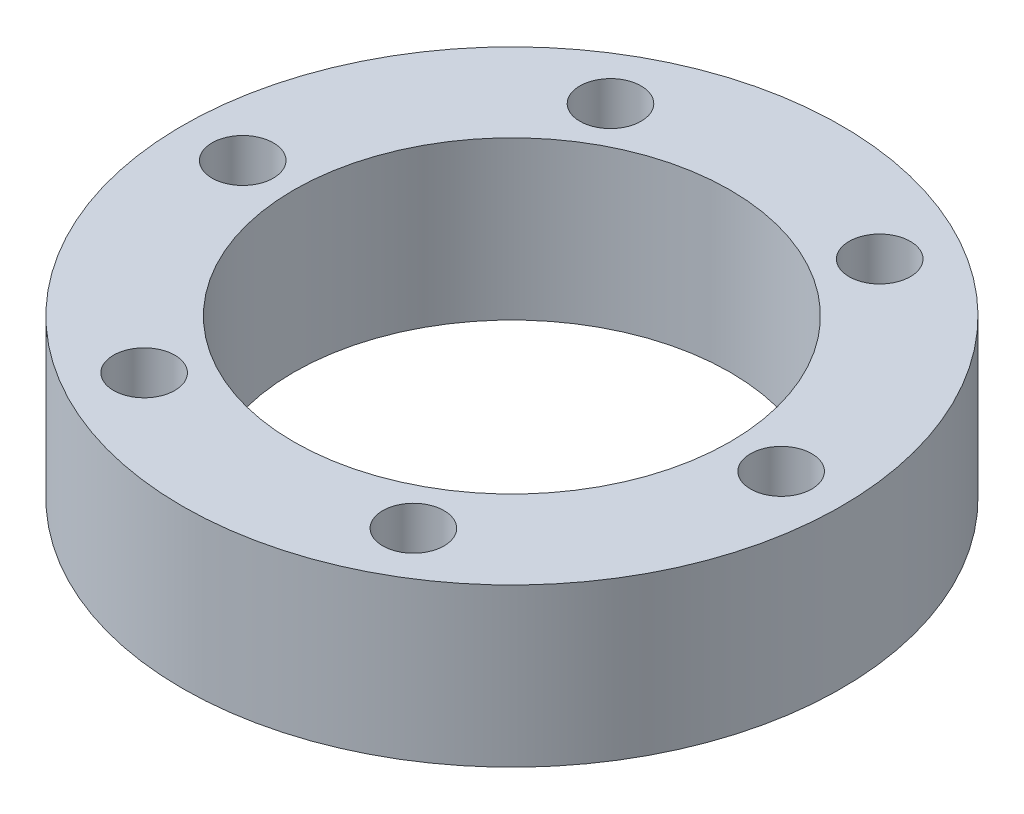
from build123d import *

# Parameters (mm, degrees)
SKETCH1_R                = 35.5
SKETCH1_R_2              = 23.5
BOSS_EXTRUDE1_DEPTH      = 17
M6_CLEARANCE_HOLE1_D     = 6.6
M6_CLEARANCE_HOLE1_DEPTH = 17
CIRPATTERN1_COUNT        = 6


with BuildPart() as part:
    # Sketch1 → Boss-Extrude1 (new body)
    with BuildSketch(Plane(origin=(0, 0, 0), x_dir=(1, 0, 0), z_dir=(0, 1, 0))):
        Circle(SKETCH1_R)
        Circle(SKETCH1_R_2, mode=Mode.SUBTRACT)
    extrude(amount=BOSS_EXTRUDE1_DEPTH)

    # M6 Clearance Hole1
    with Locations(Plane(origin=(-29, 17, 0), x_dir=(0, 0, 1), z_dir=(0, 1, 0))):
        with Locations((0, 0)):
            m6_clearance_hole1 = Hole(M6_CLEARANCE_HOLE1_D / 2, depth=M6_CLEARANCE_HOLE1_DEPTH)

    # CirPattern1: M6 Clearance Hole1 ×6 about axis
    cirpattern1_axis = Axis((0, 0, 0), (0, 1, 0))
    for i in range(1, CIRPATTERN1_COUNT):
        add(m6_clearance_hole1.rotate(cirpattern1_axis, i * 360 / CIRPATTERN1_COUNT), mode=Mode.SUBTRACT)


solid = part.part
